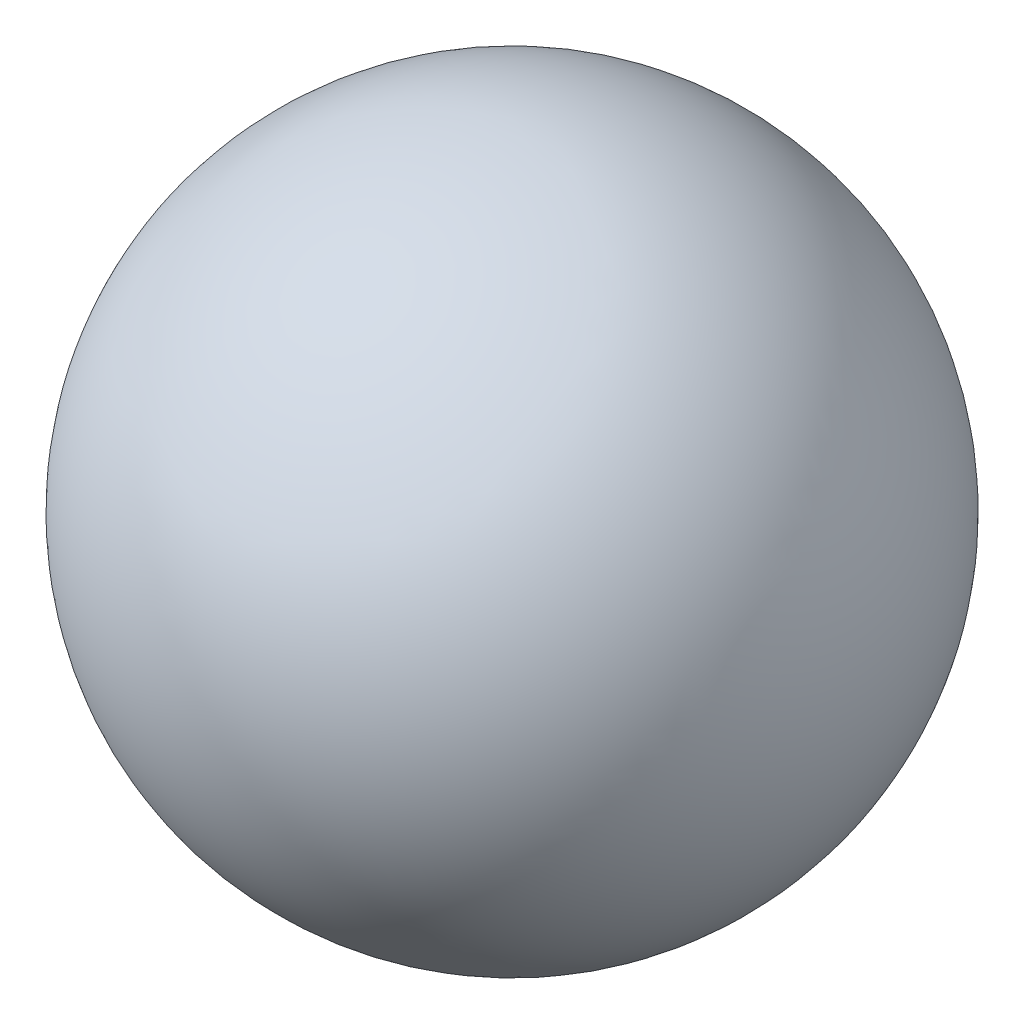
from build123d import *


with BuildPart() as part:
    # Sketch1 → Revolve1 (revolve)
    with BuildSketch(Plane.XY):
        with BuildLine():
            Line((3.6905, 9.75), (1.3095, 9.75))
            ThreePointArc((1.3095, 9.75), (2.5, 10.9405), (3.6905, 9.75))
        make_face()
    revolve(axis=Axis((3.6905, 9.75, 0), (-1, 0, 0)))


solid = part.part
